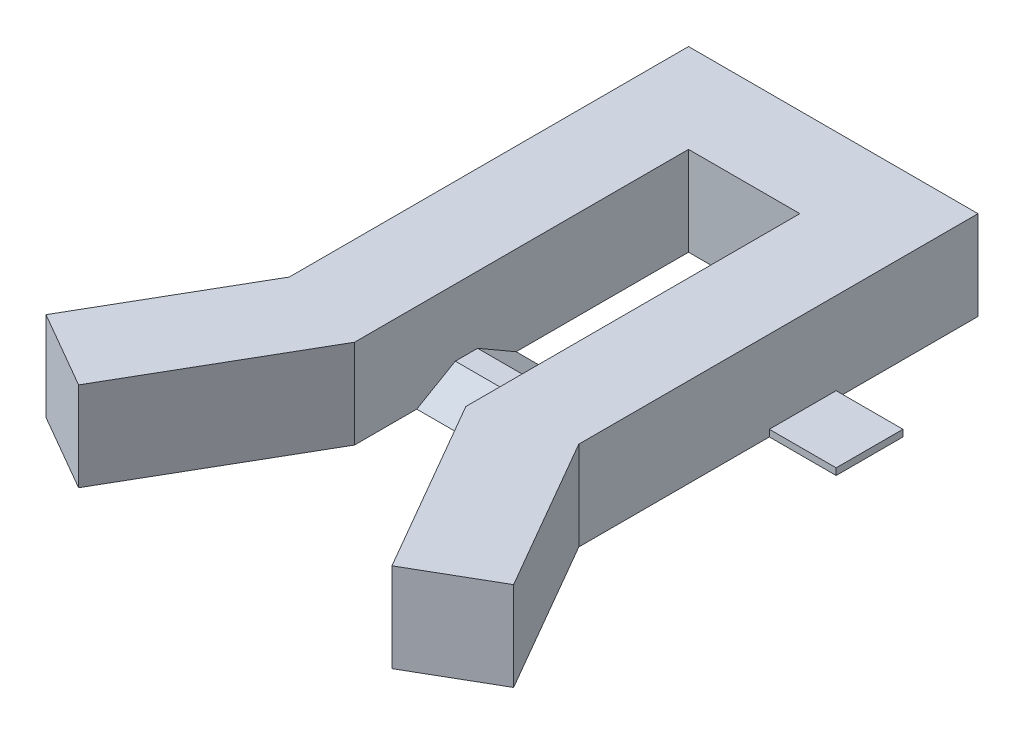
from build123d import *

# Parameters (mm, degrees)
BOSS_EXTRUDE1_DEPTH = 20
BOSS_EXTRUDE2_DEPTH = 25
SKETCH6_W           = 15
SKETCH6_H           = 15
BOSS_EXTRUDE3_DEPTH = 1.5


with BuildPart() as part:
    # Sketch2 → Boss-Extrude1 (new body)
    with BuildSketch(Plane(origin=(0, 0, 0), x_dir=(1, 0, 0), z_dir=(0, 1, 0))):
        Polygon((-35.179491924, -39.282032303), (-12.5, 0), (-12.5, 75), (0, 75), (0, 95), (-32.5, 95), (-32.5, 5.358983849), (-52.5, -29.282032303), align=None)
    boss_extrude1 = extrude(amount=BOSS_EXTRUDE1_DEPTH)

    # Mirror3: Boss-Extrude1 across plane
    add(boss_extrude1.mirror(Plane(origin=(0, 0, 0), x_dir=(0, 0, 1), z_dir=(1, 0, 0))))

    # Sketch4 → Boss-Extrude2 (add)
    with BuildSketch(Plane.ZY.offset(-12.5)):
        Polygon((-36.291651246, 0), (-27.631397208, 5), (-22.631397208, 5), (-13.97114317, 0), align=None)
    extrude(amount=BOSS_EXTRUDE2_DEPTH)

    # Sketch6 → Boss-Extrude3 (add)
    with BuildSketch(Plane.XZ):
        with Locations((-40, -55.645825623)):
            Rectangle(SKETCH6_W, SKETCH6_H)
        with Locations((40, -55.645825623)):
            Rectangle(SKETCH6_W, SKETCH6_H)
    extrude(amount=-BOSS_EXTRUDE3_DEPTH)


solid = part.part
